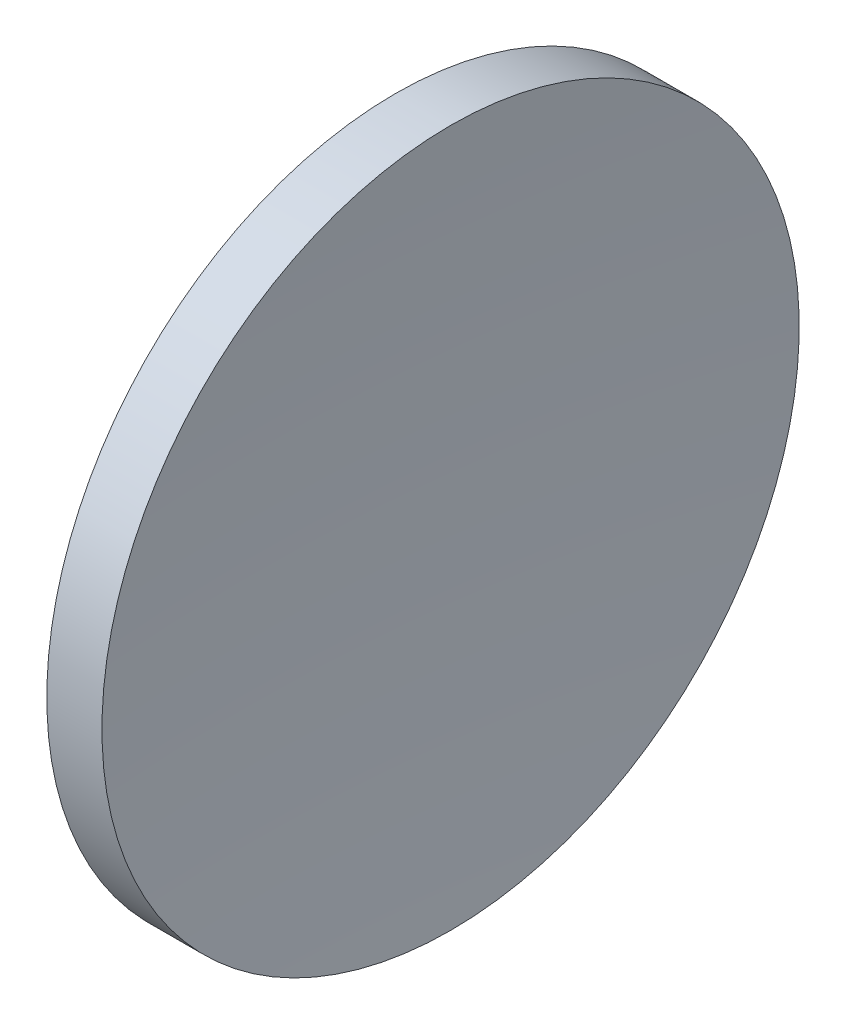
from build123d import *


with BuildPart() as part:
    # 草图1 → 旋转1 (revolve)
    with BuildSketch(Plane.XY):
        with BuildLine():
            Line((124.912627623, 84.241840471), (127.923515795, 84.241840471))
            ThreePointArc((127.923515795, 84.241840471), (127.34752312, 74.737089865), (127.155421316, 65.216840471))
            Line((127.155421316, 65.216840471), (122.855421316, 65.216840471))
            ThreePointArc((122.855421316, 65.216840471), (123.371217531, 74.784791176), (124.912627623, 84.241840471))
        make_face()
    revolve(axis=Axis((115.944491298, 65.216840471, 0), (1, 0, 0)))


solid = part.part
